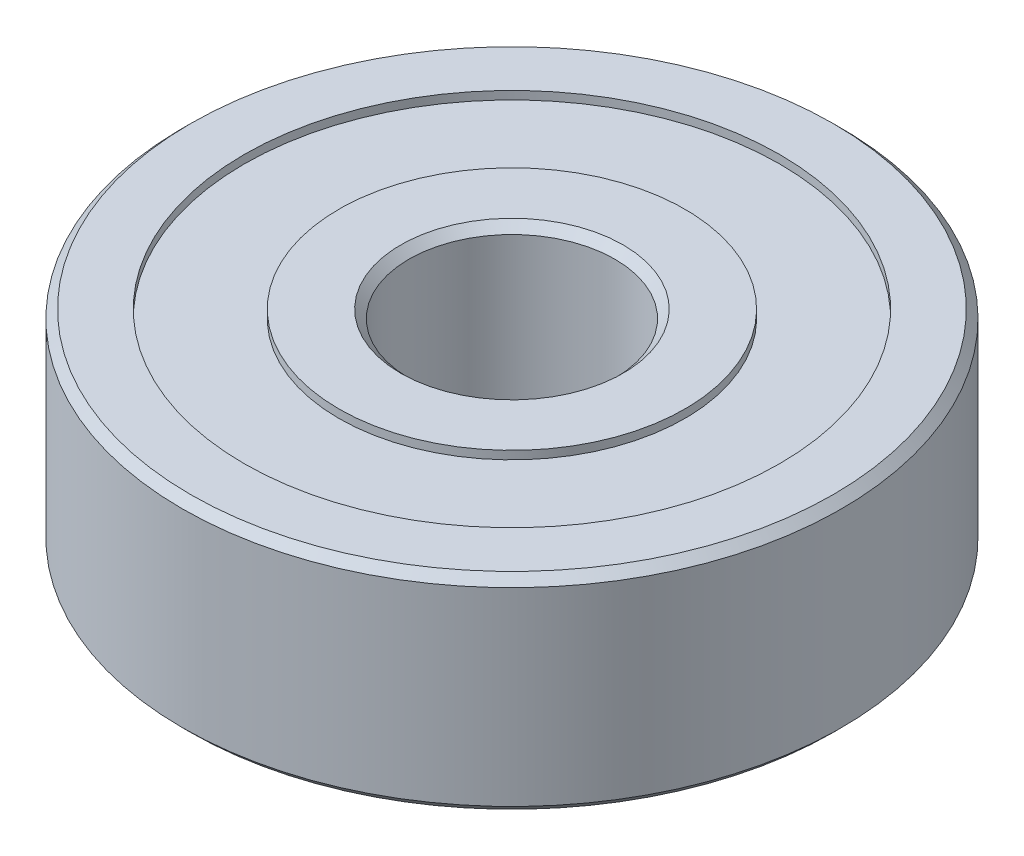
from build123d import *

# Parameters (mm, degrees)
SKETCH1_R           = 8
SKETCH1_R_2         = 2.5
BOSS_EXTRUDE1_DEPTH = 5
SKETCH2_R           = 6.5
SKETCH2_R_2         = 4.2
CUT_EXTRUDE1_DEPTH  = 0.2
SKETCH3_R           = 6.5
SKETCH3_R_2         = 4.2
CUT_EXTRUDE2_DEPTH  = 0.2
CHAMFER1_SIZE       = 0.2


with BuildPart() as part:
    # Sketch1 → Boss-Extrude1 (new body)
    with BuildSketch(Plane(origin=(0, 0, 0), x_dir=(1, 0, 0), z_dir=(0, 1, 0))):
        Circle(SKETCH1_R)
        Circle(SKETCH1_R_2, mode=Mode.SUBTRACT)
    extrude(amount=BOSS_EXTRUDE1_DEPTH)

    # Sketch2 → Cut-Extrude1 (cut)
    with BuildSketch(Plane(origin=(0, 5, 0), x_dir=(1, 0, 0), z_dir=(0, 1, 0))):
        Circle(SKETCH2_R)
        Circle(SKETCH2_R_2, mode=Mode.SUBTRACT)
    extrude(amount=-CUT_EXTRUDE1_DEPTH, mode=Mode.SUBTRACT)

    # Sketch3 → Cut-Extrude2 (cut)
    with BuildSketch(Plane.XZ):
        Circle(SKETCH3_R)
        Circle(SKETCH3_R_2, mode=Mode.SUBTRACT)
    extrude(amount=-CUT_EXTRUDE2_DEPTH, mode=Mode.SUBTRACT)

    # Chamfer1
    chamfer1_edges = [part.edges().sort_by_distance(p)[0] for p in [
        (-8, 0, 0),
        (-8, 5, 0),
        (-2.5, 0, 0),
        (-2.5, 5, 0),
    ]]
    chamfer(chamfer1_edges, length=CHAMFER1_SIZE)


solid = part.part
